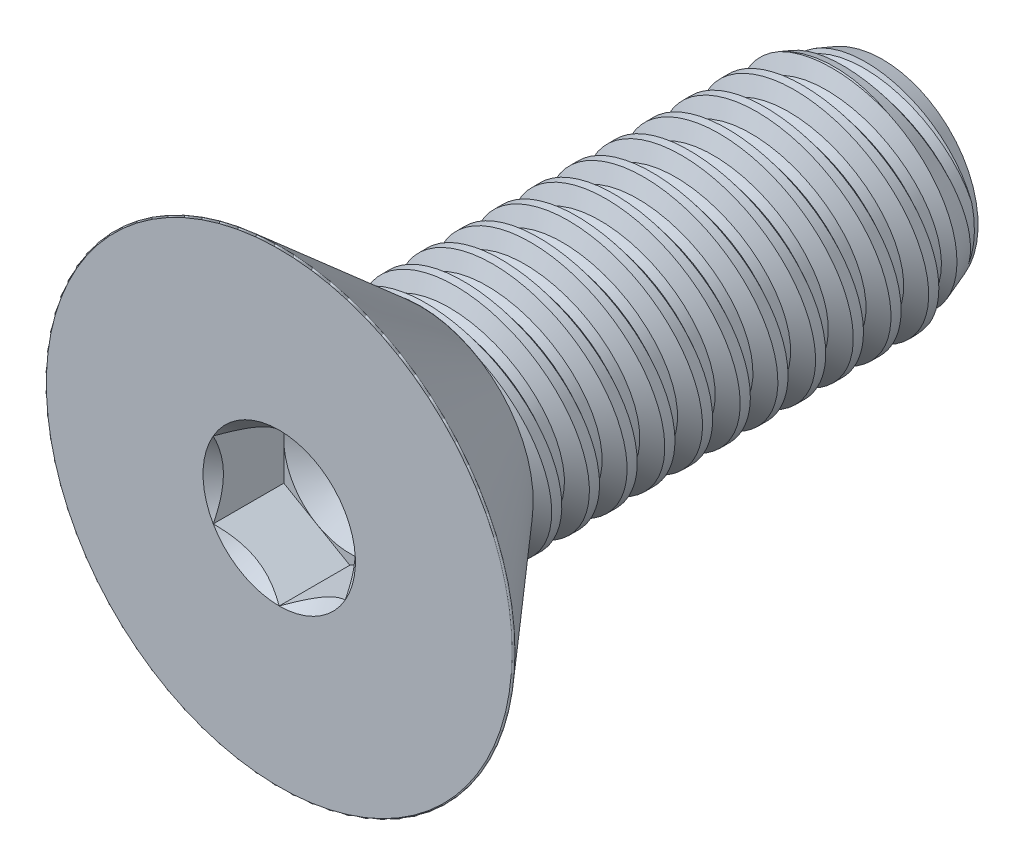
from build123d import *

# Parameters (mm, degrees)
SKETCH1_W          = 19.4564
SKETCH1_H          = 4.7625
LPATTERN1_COUNT    = 12
LPATTERN1_PITCH    = 1.5875
LPATTERN2_COUNT    = 2
LPATTERN2_PITCH    = 1.5875
SKETCH4_R          = 9.9187
EXTRUDE1_DEPTH     = 5.9436
FILLET1_R          = 0.0508
CUT_EXTRUDE1_DEPTH = 2.9718
SKETCH7_R          = 3.207902433
CUT_EXTRUDE4_DEPTH = 2.9718
CUT_EXTRUDE4_TAPER = 45
SKETCH8_R          = 2.778125
CUT_EXTRUDE5_DEPTH = 0.9906
CUT_EXTRUDE5_TAPER = 60


with BuildPart() as part:
    # Sketch1 → Revolve1 (revolve)
    with BuildSketch(Plane(origin=(0, 0, 0), x_dir=(0, 0, -1), z_dir=(1, 0, 0))):
        with Locations((9.7282, 2.38125)):
            Rectangle(SKETCH1_W, SKETCH1_H)
    revolve(axis=Axis((0, 0, 0), (0, 0, 1)))

    # Sketch2 → Cut-Revolve1 (revolve, cut)
    with BuildSketch(Plane(origin=(0, 0, 0), x_dir=(0, 0, -1), z_dir=(1, 0, 0))):
        Polygon((0.195737544, 4.795122924), (1.565900354, 5.023483392), (1.217817898, 4.094357653), (0.82634281, 4.029111805), align=None)
    cut_revolve1 = revolve(axis=Axis((0, -0.28317269, 0), (0, 0.164398987, -0.986393924)), mode=Mode.SUBTRACT)

    # Sketch3 → Cut-Revolve2 (revolve, cut)
    with BuildSketch(Plane(origin=(0, 0, 0), x_dir=(0, 0, -1), z_dir=(1, 0, 0))):
        Polygon((19.4564, 4.029111805), (17.441432495, 4.7625), (19.4564, 4.7625), align=None)
    revolve(axis=Axis((0, 0, -17.441432495), (0, 0, 1)), mode=Mode.SUBTRACT)

    # LPattern1: Cut-Revolve1 ×12
    with Locations(*[(0, 0, -i * LPATTERN1_PITCH) for i in range(1, LPATTERN1_COUNT)]):
        add(cut_revolve1, mode=Mode.SUBTRACT)

    # LPattern2: Cut-Revolve1 ×2
    with Locations(*[(0, 0, i * LPATTERN2_PITCH) for i in range(1, LPATTERN2_COUNT)]):
        add(cut_revolve1, mode=Mode.SUBTRACT)

    # Sketch4 → Extrude1 (add)
    with BuildSketch(Plane.XY):
        Circle(SKETCH4_R)
    extrude(amount=EXTRUDE1_DEPTH)

    # Sketch9 → Cut-Revolve3 (revolve, cut)
    with BuildSketch(Plane(origin=(0, 0, 0), x_dir=(0, 0, -1), z_dir=(1, 0, 0))):
        Polygon((-5.9436, 9.9187), (0, 4.752007345), (0, 9.9187), align=None)
    revolve(axis=Axis((0, 0, 0), (0, 0, 1)), mode=Mode.SUBTRACT)

    # Fillet1
    fillet1_edges = [part.edges().sort_by_distance(p)[0] for p in [
        (0, -9.9187, 5.9436),
    ]]
    fillet(fillet1_edges, radius=FILLET1_R)

    # Sketch6 → Cut-Extrude1 (cut)
    with BuildSketch(Plane.XY.offset(5.9436)):
        Polygon((0, -3.207902433), (2.778125, -1.603951217), (2.778125, 1.603951217), (0, 3.207902433), (-2.778125, 1.603951217), (-2.778125, -1.603951217), align=None)
    extrude(amount=-CUT_EXTRUDE1_DEPTH, mode=Mode.SUBTRACT)

    # Sketch7 → Cut-Extrude4 (cut)
    with BuildSketch(Plane.XY.offset(5.9436)):
        Circle(SKETCH7_R)
    extrude(amount=-CUT_EXTRUDE4_DEPTH, taper=CUT_EXTRUDE4_TAPER, mode=Mode.SUBTRACT)

    # Sketch8 → Cut-Extrude5 (cut)
    with BuildSketch(Plane.XY.offset(2.9718)):
        Circle(SKETCH8_R)
    extrude(amount=-CUT_EXTRUDE5_DEPTH, taper=CUT_EXTRUDE5_TAPER, mode=Mode.SUBTRACT)


solid = part.part
